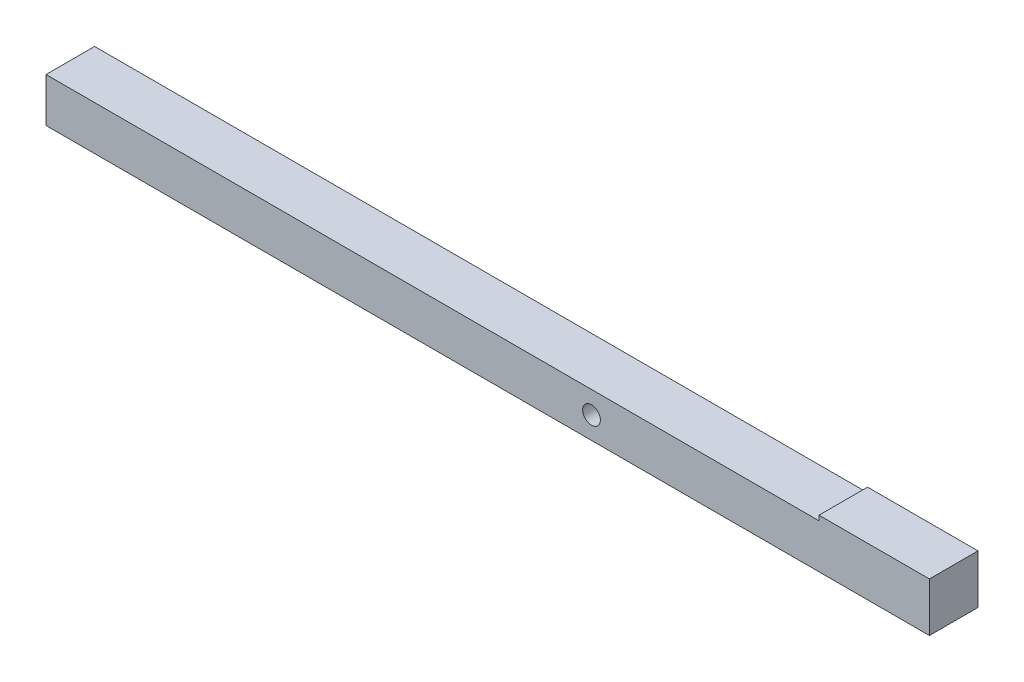
from build123d import *

# Parameters (mm, degrees)
SKETCH1_W           = 22
SKETCH1_H           = 20
BOSS_EXTRUDE1_DEPTH = 400
SKETCH2_R           = 4
CUT_EXTRUDE1_DEPTH  = 23
SKETCH3_W           = 50
SKETCH3_H           = 22
BOSS_EXTRUDE2_DEPTH = 2.2


with BuildPart() as part:
    # Sketch1 → Boss-Extrude1 (new body)
    with BuildSketch(Plane(origin=(0, 0, 0), x_dir=(0, 0, -1), z_dir=(1, 0, 0))):
        Rectangle(SKETCH1_W, SKETCH1_H)
    extrude(amount=BOSS_EXTRUDE1_DEPTH)

    # Sketch2 → Cut-Extrude1 (cut, through all)
    with BuildSketch(Plane.XY.offset(11)):
        with Locations((247, 0)):
            Circle(SKETCH2_R)
    extrude(amount=-CUT_EXTRUDE1_DEPTH, mode=Mode.SUBTRACT)

    # Sketch3 → Boss-Extrude2 (add)
    with BuildSketch(Plane(origin=(0, 10, 0), x_dir=(1, 0, 0), z_dir=(0, 1, 0))):
        with Locations((375, 0)):
            Rectangle(SKETCH3_W, SKETCH3_H)
    extrude(amount=BOSS_EXTRUDE2_DEPTH)


solid = part.part
